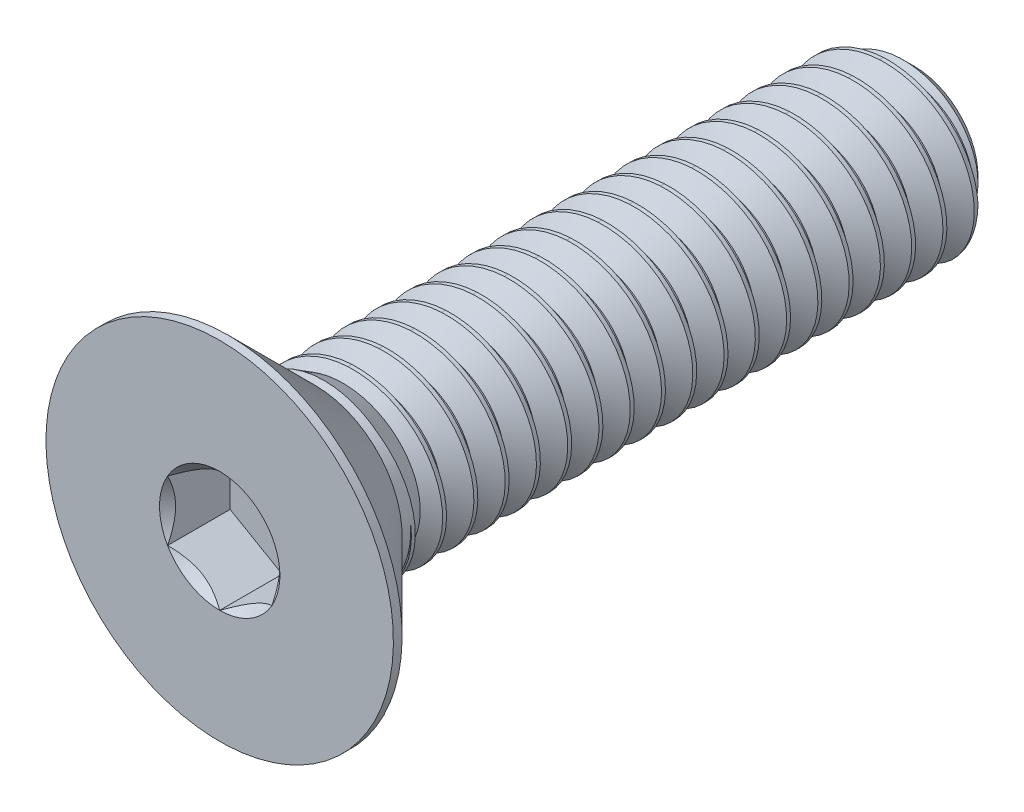
from build123d import *

# Parameters (mm, degrees)
CUT_EXTRUDE2_DEPTH = 0.9


with BuildPart() as part:
    # Sketch7 → Revolve2 (revolve)
    with BuildSketch(Plane(origin=(0, 0, 0), x_dir=(0, 0, -1), z_dir=(1, 0, 0))):
        Polygon((-1.5, 0), (-1.5, 2.5), (-1.375, 2.5), (-0.125, 1.25), (8.1625, 1.25), (8.5, 0.9125), (8.5, 0), align=None)
    revolve(axis=Axis((0, 0, -8.5), (0, 0, 1)))

    # Sketch5 → Cut-Extrude2 (cut)
    with BuildSketch(Plane.XY.offset(1.5)):
        Polygon((0.75, -0.433012702), (0.75, 0.433012702), (0, 0.866025404), (-0.75, 0.433012702), (-0.75, -0.433012702), (0, -0.866025404), align=None)
    extrude(amount=-CUT_EXTRUDE2_DEPTH, mode=Mode.SUBTRACT)

    # Cut-Extrude3 cone 1 section (through the dimple's axis) → Cut-Extrude3 (revolve, cut)
    with BuildSketch(Plane(origin=(0, 0, 1.5), x_dir=(0, -1, 0), z_dir=(1, 0, 0))):
        Polygon((0, 0), (0.866025404, 0), (0, 0.866025404), align=None)
    revolve(axis=Axis((0, 0, 1.5), (0, 0, -1)), mode=Mode.SUBTRACT)


with BuildPart() as body_2:
    # Split1: the piece on the far side of the plane
    add(part.part)
    split(bisect_by=Plane.XY, keep=Keep.BOTTOM)

    # Cut-Sweep1: sweep along a curve in space
    with BuildLine() as cut_sweep1_path:
        add(Edge.make_bspline(
            [(0, 1.25, -8.5), (-0.162690864, 1.25, -8.4906785), (-0.491626761, 1.184822675, -8.471827476), (-0.907297178, 0.906429241, -8.44371816), (-1.185395281, 0.489849727, -8.415564037), (-1.282578729, -0.001407886, -8.38742192), (-1.184285284, -0.492450866, -8.359276586), (-0.905431965, -0.9084192, -8.331132114), (-0.488548448, -1.185898083, -8.302987411), (0.002815818, -1.282585571, -8.27484277), (0.493750533, -1.183741558, -8.246698112), (0.909412541, -0.904434914, -8.218553459), (1.186433643, -0.487246228, -8.190408805), (1.282581708, 0.004223652, -8.162264151), (1.183198859, 0.495049631, -8.134119497), (0.903436115, 0.91040478, -8.105974843), (0.485943596, 1.186967775, -8.077830189), (-0.005631528, 1.282576299, -8.049685535), (-0.49634812, 1.182654734, -8.021540881), (-0.911395925, 0.902436227, -7.993396226), (-1.187500475, 0.48464038, -7.965251572), (-1.282569345, -0.007039397, -7.937106918), (-1.182109185, -0.49764601, -7.908962264), (-0.901435252, -0.912385973, -7.88081761), (-0.483336579, -1.188031745, -7.852672956), (0.008447258, -1.282560845, -7.824528302), (0.498943301, -1.181562211, -7.796383648), (0.91337492, -0.900433191, -7.768238994), (1.188561584, -0.482032196, -7.74009434), (1.2825508, 0.009855108, -7.711949686), (1.181013814, 0.500239991, -7.683805031), (0.899430045, 0.914362768, -7.655660377), (0.480727232, 1.18908999, -7.627515723), (-0.011262947, 1.282539209, -7.599371069), (-0.501536078, 1.180463993, -7.571226415), (-0.915349513, 0.898425815, -7.543081761), (-1.189616964, 0.479421689, -7.514937107), (-1.282526073, -0.012670772, -7.486792453), (-1.17991275, -0.502831561, -7.458647799), (-0.897420503, -0.916335156, -7.430503145), (-0.478115568, -1.190142504, -7.402358491), (0.014078582, -1.282511392, -7.374213836), (0.504126438, -1.179360086, -7.346069182), (0.917319694, -0.896414109, -7.317924528), (1.19066661, -0.476808871, -7.289779874), (1.282495165, 0.015486375, -7.26163522), (1.178806, 0.505420707, -7.233490566), (0.895406636, 0.918303127, -7.205345912), (0.4755016, 1.191189282, -7.177201258), (-0.016894149, 1.282477393, -7.149056604), (-0.506714367, 1.178250494, -7.12091195), (-0.919285454, 0.894398083, -7.092767296), (-1.191710518, 0.474193755, -7.064622642), (-1.282458076, -0.018301903, -7.036477987), (-1.177693568, -0.508007417, -7.008333333), (-0.893388453, -0.920266673, -6.980188679), (-0.472885339, -1.192230319, -6.952044025), (0.019709635, -1.282437214, -6.923899371), (0.509299855, -1.177135223, -6.895754717), (0.921246783, -0.892377746, -6.867610063), (1.192748682, -0.471576354, -6.839465409), (1.282414806, 0.021117343, -6.811320755), (1.17657546, 0.510591679, -6.783176101), (0.891365964, 0.922225783, -6.755031447), (0.4702668, 1.193265609, -6.726886792), (-0.022525026, 1.282390853, -6.698742138), (-0.511882888, 1.17601428, -6.670597484), (-0.923203672, 0.890353108, -6.64245283), (-1.193781098, 0.46895668, -6.614308176), (-1.282365355, -0.023932681, -6.586163522), (-1.175451682, -0.51317348, -6.558018868), (-0.889339179, -0.924180449, -6.529874214), (-0.467645994, -1.194295148, -6.50172956), (0.025340308, -1.282338312, -6.473584906), (0.514463454, -1.174887668, -6.445440252), (0.925156112, -0.888324178, -6.417295597), (1.194807759, -0.466334745, -6.389150943), (1.282309723, 0.026747904, -6.361006289), (1.174322238, 0.515752808, -6.332861635), (0.887308107, 0.92613066, -6.304716981), (0.465022934, 1.195318931, -6.276572327), (-0.028155468, 1.28227959, -6.248427673), (-0.51704154, 1.173755393, -6.220283019), (-0.927104092, 0.886290967, -6.192138365), (-1.195828663, 0.463710563, -6.163993711), (-1.282247911, -0.029562998, -6.135849057), (-1.173187134, -0.518329649, -6.107704403), (-0.88527276, -0.928076407, -6.079559748), (-0.462397633, -1.196336953, -6.051415094), (0.030970492, -1.282214688, -6.02327044), (0.519617134, -1.172617461, -5.995125786), (0.929047604, -0.884253485, -5.966981132), (1.196843802, -0.461084146, -5.938836478), (1.282179919, 0.032377949, -5.910691824), (1.172046376, 0.520903993, -5.88254717), (0.883233145, 0.930017682, -5.854402516), (0.459770104, 1.197349209, -5.826257862), (-0.033785367, 1.282143606, -5.798113208), (-0.522190224, 1.171473878, -5.769968553), (-0.930986639, 0.882211741, -5.741823899), (-1.197853173, 0.458455507, -5.713679245), (-1.282105747, -0.035192745, -5.685534591), (-1.170899969, -0.523475826, -5.657389937), (-0.881189273, -0.931954474, -5.629245283), (-0.457140358, -1.198355694, -5.601100629), (0.036600079, -1.282066344, -5.572955975), (0.524760797, -1.170324648, -5.544811321), (0.932921186, -0.880165744, -5.516666667), (1.198856771, -0.455824658, -5.488522013), (1.282025396, 0.03800737, -5.460377358), (1.169747918, 0.526045136, -5.432232704), (0.879141155, 0.933886774, -5.40408805), (0.454508409, 1.199356403, -5.375943396), (-0.039414615, 1.281982903, -5.347798742), (-0.527328841, 1.169169778, -5.319654088), (-0.934851237, 0.878115506, -5.291509434), (-1.199854591, 0.453191613, -5.26336478), (-1.281938866, -0.040821813, -5.235220126), (-1.16859023, -0.52861191, -5.207075472), (-0.877088799, -0.935814573, -5.178930818), (-0.45187427, -1.200351332, -5.150786164), (0.042228961, -1.281893284, -5.122641509), (0.529894343, -1.168009273, -5.094496855), (0.936776782, -0.876061035, -5.066352201), (1.200846628, -0.450556383, -5.038207547), (1.281846157, 0.043636059, -5.010062893), (1.167426909, 0.531176137, -4.981918239), (0.875032216, 0.937737862, -4.953773585), (0.449237952, 1.201340476, -4.925628931), (-0.045043103, 1.281797486, -4.897484277), (-0.532457291, 1.166843138, -4.869339623), (-0.938697812, 0.874002342, -4.841194969), (-1.201832877, 0.447918981, -4.813050314), (-1.28174727, -0.046450094, -4.78490566), (-1.166257962, -0.533737804, -4.756761006), (-0.872971415, -0.939656631, -4.728616352), (-0.44659947, -1.202323829, -4.700471698), (0.047857029, -1.28169551, -4.672327044), (0.535017673, -1.16567138, -4.64418239), (0.940614318, -0.871939437, -4.616037736), (1.202813333, -0.445279421, -4.587893082), (1.281642206, 0.049263906, -4.559748428), (1.165083393, 0.536296898, -4.531603774), (0.870906407, 0.941570872, -4.503459119), (0.443958835, 1.203301388, -4.475314465), (-0.050670723, 1.281587357, -4.447169811), (-0.537575477, 1.164494003, -4.419025157), (-0.942526291, 0.869872329, -4.390880503), (-1.203787992, 0.442637714, -4.362735849), (-1.281530964, -0.05207748, -4.334591195), (-1.16390321, -0.538853408, -4.306446541), (-0.868837202, -0.943480574, -4.278301887), (-0.44131606, -1.204273147, -4.250157233), (0.053484174, -1.281473027, -4.222012579), (0.540130689, -1.163311014, -4.193867925), (0.94443372, -0.867801028, -4.16572327), (1.20475685, -0.439993874, -4.137578616), (1.281413546, 0.054890803, -4.109433962), (1.162717416, 0.54140732, -4.081289308), (0.866763809, 0.945385729, -4.053144654), (0.438671158, 1.205239101, -4.025), (-0.056297366, 1.281352521, -3.996855346), (-0.542683299, 1.162122418, -3.968710692), (-0.946336598, 0.865725545, -3.940566038), (-1.205719901, 0.437347914, -3.912421384), (-1.281289952, -0.057703862, -3.88427673), (-1.161526019, -0.543958623, -3.856132075), (-0.864686238, -0.947286327, -3.827987421), (-0.436024142, -1.206199247, -3.799842767), (0.059110287, -1.281225839, -3.771698113), (0.545233292, -1.160928221, -3.743553459), (0.948234915, -0.863645889, -3.715408805), (1.20667714, -0.434699845, -3.687264151), (1.281160182, 0.060516642, -3.659119497), (1.160329024, 0.546507304, -3.630974843), (0.8626045, 0.94918236, -3.602830189), (0.433375024, 1.20715358, -3.574685535), (-0.061922924, 1.281092982, -3.546540881), (-0.547780658, 1.159728428, -3.518396226), (-0.950128662, 0.861562071, -3.490251572), (-1.207628564, 0.432049682, -3.462106918), (-1.281024238, -0.063329131, -3.433962264), (-1.159126436, -0.549053352, -3.40581761), (-0.860518604, -0.951073818, -3.377672956), (-0.430723818, -1.208102094, -3.349528302), (0.064735262, -1.28095395, -3.321383648), (0.550325384, -1.158523046, -3.293238994), (0.952017829, -0.859474101, -3.26509434), (1.208574168, -0.429397436, -3.236949686), (1.280882119, 0.066141314, -3.208805031), (1.157918261, 0.551596752, -3.180660377), (0.858428561, 0.952960693, -3.152515723), (0.428070536, 1.209044785, -3.124371069), (-0.067547288, 1.280808745, -3.096226415), (-0.552867457, 1.157312081, -3.068081761), (-0.953902408, 0.857381988, -3.039937107), (-1.209513946, 0.42674312, -3.011792453), (-1.280733827, -0.068953179, -2.983647799), (-1.156704506, -0.554137495, -2.955503145), (-0.856334381, -0.954842974, -2.927358491), (-0.42541519, -1.20998165, -2.899213836), (0.070358988, -1.280657366, -2.871069182), (0.555406865, -1.156095537, -2.842924528), (0.955782389, -0.855285742, -2.814779874), (1.210447895, -0.424086748, -2.78663522), (1.280579362, 0.071764712, -2.758490566), (1.155485175, 0.556675567, -2.730345912), (0.854236073, 0.956720653, -2.702201258), (0.422757794, 1.210912682, -2.674056604), (-0.073170349, 1.280499815, -2.64591195), (-0.557943597, 1.154873421, -2.617767296), (-0.957657764, 0.853185375, -2.589622642), (-1.21137601, 0.421428332, -2.561477987), (-1.280418725, -0.074575898, -2.533333333), (-1.154260276, -0.559210955, -2.505188679), (-0.852133648, -0.958593721, -2.477044025), (-0.420098361, -1.211837878, -2.448899371), (0.075981358, -1.280336093, -2.420754717), (0.56047764, -1.153645739, -2.392610063), (0.959528523, -0.851080895, -2.364465409), (1.212298287, -0.418767884, -2.336320755), (1.280251917, 0.077386725, -2.308176101), (1.153029813, 0.561743649, -2.280031447), (0.850027116, 0.960462169, -2.251886792), (0.417436903, 1.212757234, -2.223742138), (-0.078792, 1.280166199, -2.195597484), (-0.563008981, 1.152412497, -2.16745283), (-0.961394658, 0.848972314, -2.139308176), (-1.21321472, 0.416105419, -2.111163522), (-1.280078939, -0.08019718, -2.083018868), (-1.151793793, -0.564273635, -2.054874214), (-0.847916488, -0.962325988, -2.02672956), (-0.414773433, -1.213670745, -1.998584906), (0.081602263, -1.279990136, -1.970440252), (0.565537608, -1.151173701, -1.942295597), (0.963256158, -0.84685964, -1.914150943), (1.214125306, -0.413440947, -1.886006289), (1.27989979, 0.083007247, -1.857861635), (1.150552222, 0.566800901, -1.829716981), (0.845801772, 0.964185168, -1.801572327), (0.412107964, 1.214578405, -1.773427673), (-0.084412132, 1.279807903, -1.745283019), (-0.56806351, 1.149929356, -1.717138365), (-0.965113017, 0.844742885, -1.688993711), (-1.215030041, 0.410774483, -1.660849057), (-1.279714474, -0.085816915, -1.632704403), (-1.149305105, -0.569325435, -1.604559748), (-0.84368298, -0.966039702, -1.576415094), (-0.409440508, -1.215480212, -1.54827044), (0.087221594, -1.279619502, -1.520125786), (0.570586674, -1.148679469, -1.491981132), (0.966965223, -0.842622059, -1.463836478), (1.215928919, -0.40810604, -1.435691824), (1.279522989, 0.088626169, -1.40754717), (1.14805245, 0.571847226, -1.379402516), (0.841560122, 0.967889579, -1.351257862), (0.406771079, 1.216376161, -1.323113208), (-0.090030636, 1.279424934, -1.294968553), (-0.573107088, 1.147424046, -1.266823899), (-0.968812769, 0.840497171, -1.238679245), (-1.216821937, 0.405435629, -1.210534591), (-1.279325337, -0.091434996, -1.182389937), (-1.14679426, -0.57436626, -1.154245283), (-0.839433207, -0.969734792, -1.126100629), (-0.40409969, -1.217266247, -1.097955975), (0.092839245, -1.279224199, -1.069811321), (0.57562474, -1.146163093, -1.041666667), (0.970655646, -0.838368232, -1.013522013), (1.217709091, -0.402763264, -0.985377358), (1.27912152, 0.094243382, -0.957232704), (1.145530544, 0.576882526, -0.92908805), (0.837302247, 0.971575331, -0.900943396), (0.401426353, 1.218150467, -0.872798742), (-0.095647405, 1.279017299, -0.844654088), (-0.578139618, 1.144896615, -0.816509434), (-0.972493845, 0.836235253, -0.78836478), (-1.218590375, 0.400088958, -0.760220126), (-1.278911537, -0.097051314, -0.732075472), (-1.144261307, -0.579396012, -0.703930818), (-0.835167252, -0.973411187, -0.675786164), (-0.398751082, -1.219028815, -0.647641509), (0.098455105, -1.278804234, -0.619496855), (0.580651709, -1.143624619, -0.591352201), (0.974327356, -0.834098244, -0.563207547), (1.219465786, -0.397412724, -0.535062893), (1.27869539, 0.099858778, -0.506918239), (1.142986554, 0.581906705, -0.478773585), (0.833028231, 0.975242351, -0.450628931), (0.396073888, 1.219901288, -0.422484277), (-0.10126233, 1.278585006, -0.394339623), (-0.583161001, 1.142347112, -0.366194969), (-0.976156171, 0.831957214, -0.338050314), (-1.22033532, 0.394734575, -0.30990566), (-1.278473081, -0.102665761, -0.281761006), (-1.141706293, -0.584414594, -0.253616352), (-0.830885195, -0.977068815, -0.225471698), (-0.393394785, -1.220767881, -0.197327044), (0.104069067, -1.278359615, -0.16918239), (0.585667483, -1.141064098, -0.141037736), (0.977980282, -0.829812174, -0.112893082), (1.221198972, -0.392054522, -0.084748428), (1.278244609, 0.105472249, -0.056603774), (1.140420529, 0.586919666, -0.028459119), (0.828738154, 0.97889057, -0.000314465), (0.390713787, 1.221628591, 0.027830189), (-0.106875303, 1.278128063, 0.055974843), (-0.588171142, 1.139775585, 0.084119497), (-0.979799679, 0.827663135, 0.112264151), (-1.222056737, 0.38937258, 0.140408805), (-1.27800998, -0.108278226, 0.168553459), (-1.139129259, -0.589421917, 0.196698112), (-0.826587155, -0.980707577, 0.22484277), (-0.38803077, -1.222483526, 0.252987411), (0.10968052, -1.277889928, 0.281132114), (0.590673846, -1.138483157, 0.309276586), (0.981607336, -0.825504219, 0.33742192), (1.222934803, -0.386710737, 0.365564037), (1.277671447, 0.111165699, 0.39371816), (1.138197283, 0.591615236, 0.421827476), (0.928112945, 0.852979882, 0.4406785), (0.803484512, 0.957555554, 0.45)],
            knots=[0, 0, 0, 0, 0.003144654, 0.006289308, 0.009433962, 0.012578616, 0.01572327, 0.018867925, 0.022012579, 0.025157233, 0.028301887, 0.031446541, 0.034591195, 0.037735849, 0.040880503, 0.044025157, 0.047169811, 0.050314465, 0.053459119, 0.056603774, 0.059748428, 0.062893082, 0.066037736, 0.06918239, 0.072327044, 0.075471698, 0.078616352, 0.081761006, 0.08490566, 0.088050314, 0.091194969, 0.094339623, 0.097484277, 0.100628931, 0.103773585, 0.106918239, 0.110062893, 0.113207547, 0.116352201, 0.119496855, 0.122641509, 0.125786164, 0.128930818, 0.132075472, 0.135220126, 0.13836478, 0.141509434, 0.144654088, 0.147798742, 0.150943396, 0.15408805, 0.157232704, 0.160377358, 0.163522013, 0.166666667, 0.169811321, 0.172955975, 0.176100629, 0.179245283, 0.182389937, 0.185534591, 0.188679245, 0.191823899, 0.194968553, 0.198113208, 0.201257862, 0.204402516, 0.20754717, 0.210691824, 0.213836478, 0.216981132, 0.220125786, 0.22327044, 0.226415094, 0.229559748, 0.232704403, 0.235849057, 0.238993711, 0.242138365, 0.245283019, 0.248427673, 0.251572327, 0.254716981, 0.257861635, 0.261006289, 0.264150943, 0.267295597, 0.270440252, 0.273584906, 0.27672956, 0.279874214, 0.283018868, 0.286163522, 0.289308176, 0.29245283, 0.295597484, 0.298742138, 0.301886792, 0.305031447, 0.308176101, 0.311320755, 0.314465409, 0.317610063, 0.320754717, 0.323899371, 0.327044025, 0.330188679, 0.333333333, 0.336477987, 0.339622642, 0.342767296, 0.34591195, 0.349056604, 0.352201258, 0.355345912, 0.358490566, 0.36163522, 0.364779874, 0.367924528, 0.371069182, 0.374213836, 0.377358491, 0.380503145, 0.383647799, 0.386792453, 0.389937107, 0.393081761, 0.396226415, 0.399371069, 0.402515723, 0.405660377, 0.408805031, 0.411949686, 0.41509434, 0.418238994, 0.421383648, 0.424528302, 0.427672956, 0.43081761, 0.433962264, 0.437106918, 0.440251572, 0.443396226, 0.446540881, 0.449685535, 0.452830189, 0.455974843, 0.459119497, 0.462264151, 0.465408805, 0.468553459, 0.471698113, 0.474842767, 0.477987421, 0.481132075, 0.48427673, 0.487421384, 0.490566038, 0.493710692, 0.496855346, 0.5, 0.503144654, 0.506289308, 0.509433962, 0.512578616, 0.51572327, 0.518867925, 0.522012579, 0.525157233, 0.528301887, 0.531446541, 0.534591195, 0.537735849, 0.540880503, 0.544025157, 0.547169811, 0.550314465, 0.553459119, 0.556603774, 0.559748428, 0.562893082, 0.566037736, 0.56918239, 0.572327044, 0.575471698, 0.578616352, 0.581761006, 0.58490566, 0.588050314, 0.591194969, 0.594339623, 0.597484277, 0.600628931, 0.603773585, 0.606918239, 0.610062893, 0.613207547, 0.616352201, 0.619496855, 0.622641509, 0.625786164, 0.628930818, 0.632075472, 0.635220126, 0.63836478, 0.641509434, 0.644654088, 0.647798742, 0.650943396, 0.65408805, 0.657232704, 0.660377358, 0.663522013, 0.666666667, 0.669811321, 0.672955975, 0.676100629, 0.679245283, 0.682389937, 0.685534591, 0.688679245, 0.691823899, 0.694968553, 0.698113208, 0.701257862, 0.704402516, 0.70754717, 0.710691824, 0.713836478, 0.716981132, 0.720125786, 0.72327044, 0.726415094, 0.729559748, 0.732704403, 0.735849057, 0.738993711, 0.742138365, 0.745283019, 0.748427673, 0.751572327, 0.754716981, 0.757861635, 0.761006289, 0.764150943, 0.767295597, 0.770440252, 0.773584906, 0.77672956, 0.779874214, 0.783018868, 0.786163522, 0.789308176, 0.79245283, 0.795597484, 0.798742138, 0.801886792, 0.805031447, 0.808176101, 0.811320755, 0.814465409, 0.817610063, 0.820754717, 0.823899371, 0.827044025, 0.830188679, 0.833333333, 0.836477987, 0.839622642, 0.842767296, 0.84591195, 0.849056604, 0.852201258, 0.855345912, 0.858490566, 0.86163522, 0.864779874, 0.867924528, 0.871069182, 0.874213836, 0.877358491, 0.880503145, 0.883647799, 0.886792453, 0.889937107, 0.893081761, 0.896226415, 0.899371069, 0.902515723, 0.905660377, 0.908805031, 0.911949686, 0.91509434, 0.918238994, 0.921383648, 0.924528302, 0.927672956, 0.93081761, 0.933962264, 0.937106918, 0.940251572, 0.943396226, 0.946540881, 0.949685535, 0.952830189, 0.955974843, 0.959119497, 0.962264151, 0.965408805, 0.968553459, 0.971698113, 0.974842767, 0.977987421, 0.981132075, 0.98427673, 0.987421384, 0.990566038, 0.993710692, 0.996855346, 1, 1, 1, 1], degree=3))
    # Sketch8 → Cut-Sweep1 (sweep, cut)
    with BuildSketch(Plane(origin=(0, 0, 0), x_dir=(0, 0, -1), z_dir=(1, 0, 0))):
        Polygon((8.4859375, 1.274356964), (8.9078125, 1.274356964), (8.725, 0.957716426), (8.66875, 0.957716426), align=None)
    sweep(path=cut_sweep1_path.line, is_frenet=True, mode=Mode.SUBTRACT)


with BuildPart() as part_1:
    add(part.part)

    # Split1
    split(bisect_by=Plane.XY, keep=Keep.TOP)

    add(body_2.part)  # Boss-Extrude1 merges body 2
    # Boss-Extrude1 cone 1 section (through the dimple's axis) → Boss-Extrude1 (revolve)
    with BuildSketch(Plane(origin=(0, 0, 0), x_dir=(0, -1, 0), z_dir=(1, 0, 0))):
        Polygon((0, 0), (1.25, 0), (0, 2.088597806), align=None)
    revolve(axis=Axis((0, 0, 0), (0, 0, -1)))


solid = part_1.part
